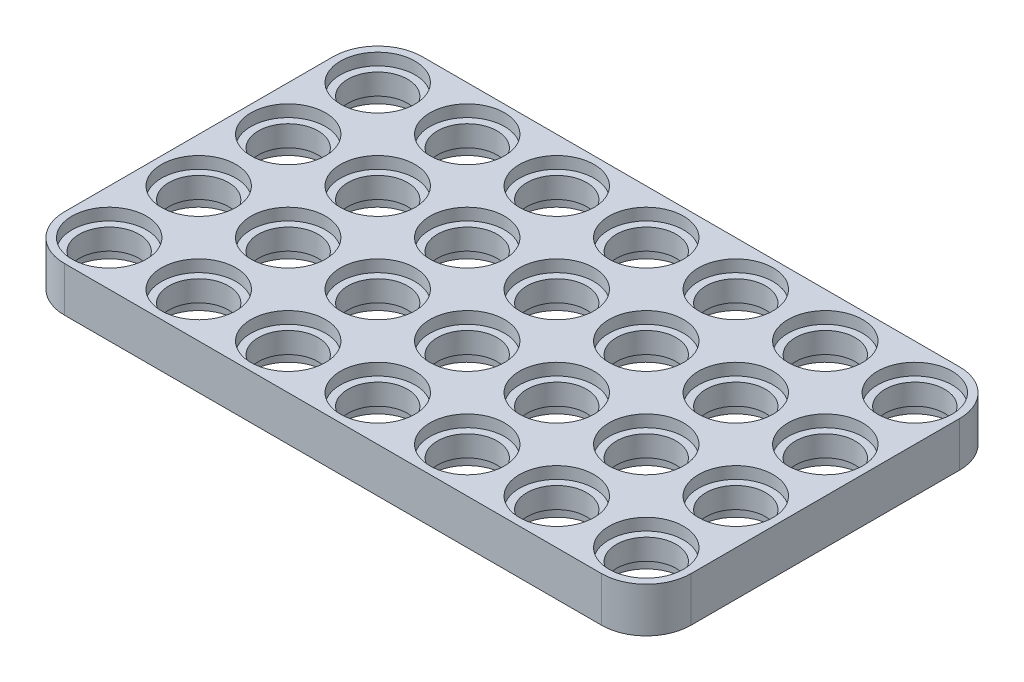
from build123d import *

# Parameters (mm, degrees)
SKETCH1_W               = 42
SKETCH1_H               = 24
BOSS_EXTRUDE1_DEPTH     = 1.5
FILLET1_R               = 3
SKETCH2_R               = 2
CUT_EXTRUDE1_DEPTH      = 4
SKETCH3_R               = 2.5
CUT_EXTRUDE2_DEPTH      = 0.8
MIRROR2_COPY_1_SKETCH_R = 2.5
MIRROR2_COPY_1_DEPTH    = 0.8


with BuildPart() as part:
    # Sketch1 → Boss-Extrude1 (new body, symmetric)
    with BuildSketch(Plane(origin=(0, 0, 0), x_dir=(1, 0, 0), z_dir=(0, 1, 0))):
        Rectangle(SKETCH1_W, SKETCH1_H)
    extrude(amount=BOSS_EXTRUDE1_DEPTH, both=True)

    # Fillet1
    fillet1_edges = [part.edges().sort_by_distance(p)[0] for p in [
        (-21, 0, -12),
        (21, 0, -12),
        (21, 0, 12),
        (-21, 0, 12),
    ]]
    fillet(fillet1_edges, radius=FILLET1_R)

    # Sketch2 → Cut-Extrude1 (cut, through all)
    with BuildSketch(Plane(origin=(0, 1.5, 0), x_dir=(1, 0, 0), z_dir=(0, 1, 0))):
        with Locations((-18, 9)):
            Circle(SKETCH2_R)
        with Locations((-12, 9)):
            Circle(SKETCH2_R)
        with Locations((-6, 9)):
            Circle(SKETCH2_R)
        with Locations((0, 9)):
            Circle(SKETCH2_R)
        with Locations((6, 9)):
            Circle(SKETCH2_R)
        with Locations((12, 9)):
            Circle(SKETCH2_R)
        with Locations((18, 9)):
            Circle(SKETCH2_R)
        with Locations((-12, 3)):
            Circle(SKETCH2_R)
        with Locations((-6, 3)):
            Circle(SKETCH2_R)
        with Locations((0, 3)):
            Circle(SKETCH2_R)
        with Locations((6, 3)):
            Circle(SKETCH2_R)
        with Locations((12, 3)):
            Circle(SKETCH2_R)
        with Locations((18, 3)):
            Circle(SKETCH2_R)
        with Locations((-12, -3)):
            Circle(SKETCH2_R)
        with Locations((-6, -3)):
            Circle(SKETCH2_R)
        with Locations((0, -3)):
            Circle(SKETCH2_R)
        with Locations((6, -3)):
            Circle(SKETCH2_R)
        with Locations((12, -3)):
            Circle(SKETCH2_R)
        with Locations((18, -3)):
            Circle(SKETCH2_R)
        with Locations((-18, 3)):
            Circle(SKETCH2_R)
        with Locations((-18, -3)):
            Circle(SKETCH2_R)
    cut_extrude1 = extrude(amount=-CUT_EXTRUDE1_DEPTH, mode=Mode.SUBTRACT)

    # Sketch3 → Cut-Extrude2 (cut)
    with BuildSketch(Plane(origin=(0, 1.5, 0), x_dir=(1, 0, 0), z_dir=(0, 1, 0))):
        with Locations((-18, 9)):
            Circle(SKETCH3_R)
        with Locations((-12, 9)):
            Circle(SKETCH3_R)
        with Locations((-6, 9)):
            Circle(SKETCH3_R)
        with Locations((0, 9)):
            Circle(SKETCH3_R)
        with Locations((6, 9)):
            Circle(SKETCH3_R)
        with Locations((12, 9)):
            Circle(SKETCH3_R)
        with Locations((18, 9)):
            Circle(SKETCH3_R)
        with Locations((-12, 3)):
            Circle(SKETCH3_R)
        with Locations((-6, 3)):
            Circle(SKETCH3_R)
        with Locations((0, 3)):
            Circle(SKETCH3_R)
        with Locations((6, 3)):
            Circle(SKETCH3_R)
        with Locations((12, 3)):
            Circle(SKETCH3_R)
        with Locations((18, 3)):
            Circle(SKETCH3_R)
        with Locations((-12, -3)):
            Circle(SKETCH3_R)
        with Locations((-6, -3)):
            Circle(SKETCH3_R)
        with Locations((0, -3)):
            Circle(SKETCH3_R)
        with Locations((6, -3)):
            Circle(SKETCH3_R)
        with Locations((12, -3)):
            Circle(SKETCH3_R)
        with Locations((18, -3)):
            Circle(SKETCH3_R)
        with Locations((-18, 3)):
            Circle(SKETCH3_R)
        with Locations((-18, -3)):
            Circle(SKETCH3_R)
    cut_extrude2 = extrude(amount=-CUT_EXTRUDE2_DEPTH, mode=Mode.SUBTRACT)

    # Mirror1: Cut-Extrude2 across plane
    add(cut_extrude2.mirror(Plane.ZX), mode=Mode.SUBTRACT)

    # Mirror2: Cut-Extrude1, Cut-Extrude2 across plane
    add(cut_extrude1.mirror(Plane.XY), mode=Mode.SUBTRACT)
    add(cut_extrude2.mirror(Plane.XY), mode=Mode.SUBTRACT)

    # Mirror2 copy 1 sketch → Mirror2 copy 1 (cut)
    with BuildSketch(Plane.XZ.offset(1.5)):
        with Locations((-18, 9)):
            Circle(MIRROR2_COPY_1_SKETCH_R)
        with Locations((-12, 9)):
            Circle(MIRROR2_COPY_1_SKETCH_R)
        with Locations((-6, 9)):
            Circle(MIRROR2_COPY_1_SKETCH_R)
        with Locations((0, 9)):
            Circle(MIRROR2_COPY_1_SKETCH_R)
        with Locations((6, 9)):
            Circle(MIRROR2_COPY_1_SKETCH_R)
        with Locations((12, 9)):
            Circle(MIRROR2_COPY_1_SKETCH_R)
        with Locations((18, 9)):
            Circle(MIRROR2_COPY_1_SKETCH_R)
        with Locations((-12, 3)):
            Circle(MIRROR2_COPY_1_SKETCH_R)
        with Locations((-6, 3)):
            Circle(MIRROR2_COPY_1_SKETCH_R)
        with Locations((0, 3)):
            Circle(MIRROR2_COPY_1_SKETCH_R)
        with Locations((6, 3)):
            Circle(MIRROR2_COPY_1_SKETCH_R)
        with Locations((12, 3)):
            Circle(MIRROR2_COPY_1_SKETCH_R)
        with Locations((18, 3)):
            Circle(MIRROR2_COPY_1_SKETCH_R)
        with Locations((-12, -3)):
            Circle(MIRROR2_COPY_1_SKETCH_R)
        with Locations((-6, -3)):
            Circle(MIRROR2_COPY_1_SKETCH_R)
        with Locations((0, -3)):
            Circle(MIRROR2_COPY_1_SKETCH_R)
        with Locations((6, -3)):
            Circle(MIRROR2_COPY_1_SKETCH_R)
        with Locations((12, -3)):
            Circle(MIRROR2_COPY_1_SKETCH_R)
        with Locations((18, -3)):
            Circle(MIRROR2_COPY_1_SKETCH_R)
        with Locations((-18, 3)):
            Circle(MIRROR2_COPY_1_SKETCH_R)
        with Locations((-18, -3)):
            Circle(MIRROR2_COPY_1_SKETCH_R)
    extrude(amount=-MIRROR2_COPY_1_DEPTH, mode=Mode.SUBTRACT)


solid = part.part
